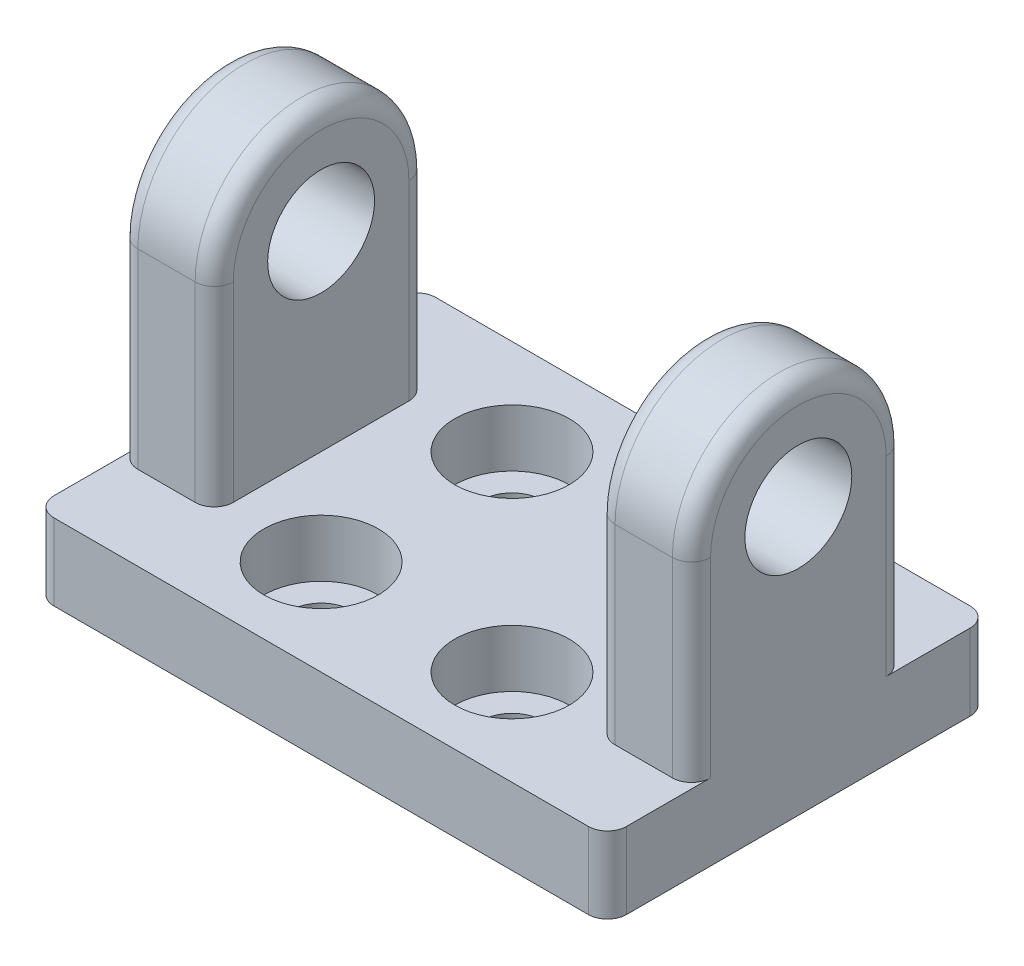
from build123d import *

# Parameters (mm, degrees)
ESQUISSE2_R             = 2.8
BOSS_EXTRU_1_DEPTH      = 15
ESQUISSE4_W             = 30
ESQUISSE4_H             = 20
BOSS_EXTRU_2_DEPTH      = 4
ENL_V_MAT_EXTRU_1_REACH = 6
ESQUISSE5_R             = 1.6
ESQUISSE6_W             = 20
ESQUISSE6_H             = 21.543710407
ENL_V_MAT_EXTRU_2_DEPTH = 16.6
ESQUISSE7_R             = 3
ENL_V_MAT_EXTRU_3_DEPTH = 3
CONG_1_R                = 1


with BuildPart() as part:
    # Esquisse2 → Boss.-Extru.1 (new body, symmetric)
    with BuildSketch(Plane(origin=(0, 0, 0), x_dir=(0, 0, -1), z_dir=(1, 0, 0))):
        with BuildLine():
            Line((5.6, 0), (5.6, -10))
            Line((5.6, -10), (-5.6, -10))
            Line((-5.6, -10), (-5.6, 0))
            ThreePointArc((-5.6, 0), (0, 5.6), (5.6, 0))
        make_face()
        Circle(ESQUISSE2_R, mode=Mode.SUBTRACT)
    extrude(amount=BOSS_EXTRU_1_DEPTH, both=True)

    # Esquisse4 → Boss.-Extru.2 (add)
    with BuildSketch(Plane.XZ.offset(10)):
        Rectangle(ESQUISSE4_W, ESQUISSE4_H)
    extrude(amount=BOSS_EXTRU_2_DEPTH)

    # Esquisse5 → Enlèv. mat.-Extru.1 (cut, up to next)
    with BuildSketch(Plane(origin=(0, -10, 0), x_dir=(1, 0, 0), z_dir=(0, 1, 0)), mode=Mode.PRIVATE) as enl_v_mat_extru_1_sk1:
        with Locations(Location((5, -5, 0), (0, 0, 270))):  # turned: the seam where the file's is
            Circle(ESQUISSE5_R)
    enl_v_mat_extru_1_tool1 = extrude(enl_v_mat_extru_1_sk1.sketch, amount=-ENL_V_MAT_EXTRU_1_REACH, mode=Mode.PRIVATE) & part.part
    add(enl_v_mat_extru_1_tool1.solids().sort_by_distance((5, -10, 5))[0], mode=Mode.SUBTRACT)
    # Esquisse5 → Enlèv. mat.-Extru.1 (cut, up to next)
    with BuildSketch(Plane(origin=(0, -10, 0), x_dir=(1, 0, 0), z_dir=(0, 1, 0)), mode=Mode.PRIVATE) as enl_v_mat_extru_1_sk2:
        with Locations(Location((5, 5, 0), (0, 0, 270))):  # turned: the seam where the file's is
            Circle(ESQUISSE5_R)
    enl_v_mat_extru_1_tool2 = extrude(enl_v_mat_extru_1_sk2.sketch, amount=-ENL_V_MAT_EXTRU_1_REACH, mode=Mode.PRIVATE) & part.part
    add(enl_v_mat_extru_1_tool2.solids().sort_by_distance((5, -10, -5))[0], mode=Mode.SUBTRACT)
    # Esquisse5 → Enlèv. mat.-Extru.1 (cut, up to next)
    with BuildSketch(Plane(origin=(0, -10, 0), x_dir=(1, 0, 0), z_dir=(0, 1, 0)), mode=Mode.PRIVATE) as enl_v_mat_extru_1_sk3:
        with Locations(Location((-5, 5, 0), (0, 0, 270))):  # turned: the seam where the file's is
            Circle(ESQUISSE5_R)
    enl_v_mat_extru_1_tool3 = extrude(enl_v_mat_extru_1_sk3.sketch, amount=-ENL_V_MAT_EXTRU_1_REACH, mode=Mode.PRIVATE) & part.part
    add(enl_v_mat_extru_1_tool3.solids().sort_by_distance((-5, -10, -5))[0], mode=Mode.SUBTRACT)
    # Esquisse5 → Enlèv. mat.-Extru.1 (cut, up to next)
    with BuildSketch(Plane(origin=(0, -10, 0), x_dir=(1, 0, 0), z_dir=(0, 1, 0)), mode=Mode.PRIVATE) as enl_v_mat_extru_1_sk4:
        with Locations(Location((-5, -5, 0), (0, 0, 270))):  # turned: the seam where the file's is
            Circle(ESQUISSE5_R)
    enl_v_mat_extru_1_tool4 = extrude(enl_v_mat_extru_1_sk4.sketch, amount=-ENL_V_MAT_EXTRU_1_REACH, mode=Mode.PRIVATE) & part.part
    add(enl_v_mat_extru_1_tool4.solids().sort_by_distance((-5, -10, 5))[0], mode=Mode.SUBTRACT)

    # Esquisse6 → Enlèv. mat.-Extru.2 (cut, through all)
    with BuildSketch(Plane.XY.offset(5.6)):
        with Locations((0, 0.771855204)):
            Rectangle(ESQUISSE6_W, ESQUISSE6_H)
    extrude(amount=-ENL_V_MAT_EXTRU_2_DEPTH, mode=Mode.SUBTRACT)

    # Esquisse7 → Enlèv. mat.-Extru.3 (cut)
    with BuildSketch(Plane(origin=(0, -10, 0), x_dir=(1, 0, 0), z_dir=(0, 1, 0))):
        with Locations(Location((-5, 5, 0), (0, 0, 270))):  # turned: the seam where the file's is
            Circle(ESQUISSE7_R)
        with Locations(Location((5, 5, 0), (0, 0, 270))):  # turned: the seam where the file's is
            Circle(ESQUISSE7_R)
        with Locations(Location((5, -5, 0), (0, 0, 270))):  # turned: the seam where the file's is
            Circle(ESQUISSE7_R)
        with Locations(Location((-5, -5, 0), (0, 0, 270))):  # turned: the seam where the file's is
            Circle(ESQUISSE7_R)
    extrude(amount=-ENL_V_MAT_EXTRU_3_DEPTH, mode=Mode.SUBTRACT)

    # Congé1
    cong_1_edges = [part.edges().sort_by_distance(p)[0] for p in [
        (15, -5, -5.6),
        (-15, -12, 10),
        (-15, -12, -10),
        (15, -12, -10),
        (15, -12, 10),
        (15, 5.6, 0),
        (-15, -5, -5.6),
        (-15, -5, 5.6),
        (-15, 5.6, 0),
        (-10, 5.6, 0),
        (-10, -5, -5.6),
        (10, -5, -5.6),
        (10, 5.6, 0),
        (10, -5, 5.6),
        (-10, -5, 5.6),
        (15, -5, 5.6),
    ]]
    fillet(cong_1_edges, radius=CONG_1_R)


solid = part.part
